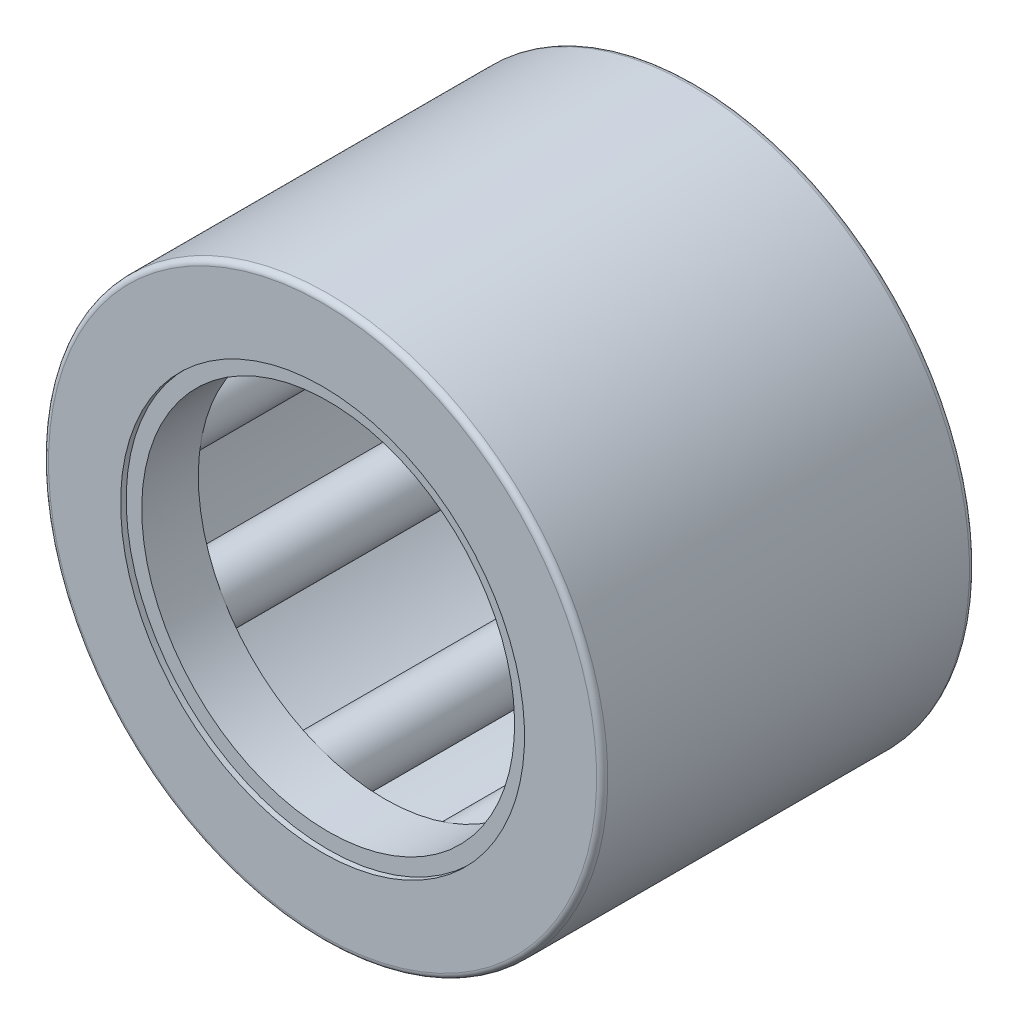
from build123d import *

# Parameters (mm, degrees)
SKETCH2_W         = 5.333333334
SKETCH2_H         = 0.5
SKETCH3_W         = 6.666666666
SKETCH3_H         = 0.166666666
CIRPATTERN1_COUNT = 9
CIRPATTERN1_ANGLE = 320
FILLET1_R         = 0.12
SKETCH4_W         = 1.213333333
SKETCH4_H         = 0.333333333
SKETCH5_W         = 1.213333333
SKETCH5_H         = 0.333333333


with BuildPart() as part:
    # Sketch7 → Revolve1 (revolve)
    with BuildSketch(Plane(origin=(0, 0, 0), x_dir=(0, 0, -1), z_dir=(1, 0, 0))):
        Polygon((-4, 6), (-4, 4.333333333), (-3.333333333, 4.333333333), (-3.333333333, 5.333333333), (3.333333333, 5.333333333), (3.333333333, 4.333333333), (4, 4.333333333), (4, 6), align=None)
    revolve(axis=Axis((0, 0, 4), (0, 0, -1)))

    # Fillet1
    fillet1_edges = [part.edges().sort_by_distance(p)[0] for p in [
        (0, -6, -4),
        (0, -6, 4),
    ]]
    fillet(fillet1_edges, radius=FILLET1_R)


with BuildPart() as body_2:
    # Sketch2 → Revolve2 (revolve)
    with BuildSketch(Plane(origin=(0, 0, 0), x_dir=(0, 0, -1), z_dir=(1, 0, 0))):
        with Locations((0, 5.083333333)):
            Rectangle(SKETCH2_W, SKETCH2_H)
    revolve(axis=Axis((0, 4.666666667, 2.666666667), (0, 0, -1)))


with BuildPart() as body_3:
    # Sketch3 → Revolve3 (revolve)
    with BuildSketch(Plane(origin=(0, 0, 0), x_dir=(0, 0, -1), z_dir=(1, 0, 0))):
        with Locations((0, 4.75)):
            Rectangle(SKETCH3_W, SKETCH3_H)
    revolve(axis=Axis((0, 4.666666667, 3.333333333), (0, 0, -1)))


with BuildPart() as cirpattern1_1:
    # CirPattern1: pattern copy
    add(body_2.part.rotate(Axis((0, 0, 4), (0, 0, -1)), 1 * CIRPATTERN1_ANGLE / (CIRPATTERN1_COUNT - 1)))


with BuildPart() as cirpattern1_2:
    # CirPattern1: pattern copy
    add(body_2.part.rotate(Axis((0, 0, 4), (0, 0, -1)), 2 * CIRPATTERN1_ANGLE / (CIRPATTERN1_COUNT - 1)))


with BuildPart() as cirpattern1_3:
    # CirPattern1: pattern copy
    add(body_2.part.rotate(Axis((0, 0, 4), (0, 0, -1)), 3 * CIRPATTERN1_ANGLE / (CIRPATTERN1_COUNT - 1)))


with BuildPart() as cirpattern1_4:
    # CirPattern1: pattern copy
    add(body_2.part.rotate(Axis((0, 0, 4), (0, 0, -1)), 4 * CIRPATTERN1_ANGLE / (CIRPATTERN1_COUNT - 1)))


with BuildPart() as cirpattern1_5:
    # CirPattern1: pattern copy
    add(body_2.part.rotate(Axis((0, 0, 4), (0, 0, -1)), 5 * CIRPATTERN1_ANGLE / (CIRPATTERN1_COUNT - 1)))


with BuildPart() as cirpattern1_6:
    # CirPattern1: pattern copy
    add(body_2.part.rotate(Axis((0, 0, 4), (0, 0, -1)), 6 * CIRPATTERN1_ANGLE / (CIRPATTERN1_COUNT - 1)))


with BuildPart() as cirpattern1_7:
    # CirPattern1: pattern copy
    add(body_2.part.rotate(Axis((0, 0, 4), (0, 0, -1)), 7 * CIRPATTERN1_ANGLE / (CIRPATTERN1_COUNT - 1)))


with BuildPart() as cirpattern1_8:
    # CirPattern1: pattern copy
    add(body_2.part.rotate(Axis((0, 0, 4), (0, 0, -1)), 8 * CIRPATTERN1_ANGLE / (CIRPATTERN1_COUNT - 1)))


with BuildPart() as cirpattern1_9:
    # CirPattern1: pattern copy
    add(body_3.part.rotate(Axis((0, 0, 4), (0, 0, -1)), 1 * CIRPATTERN1_ANGLE / (CIRPATTERN1_COUNT - 1)))


with BuildPart() as cirpattern1_10:
    # CirPattern1: pattern copy
    add(body_3.part.rotate(Axis((0, 0, 4), (0, 0, -1)), 2 * CIRPATTERN1_ANGLE / (CIRPATTERN1_COUNT - 1)))


with BuildPart() as cirpattern1_11:
    # CirPattern1: pattern copy
    add(body_3.part.rotate(Axis((0, 0, 4), (0, 0, -1)), 3 * CIRPATTERN1_ANGLE / (CIRPATTERN1_COUNT - 1)))


with BuildPart() as cirpattern1_12:
    # CirPattern1: pattern copy
    add(body_3.part.rotate(Axis((0, 0, 4), (0, 0, -1)), 4 * CIRPATTERN1_ANGLE / (CIRPATTERN1_COUNT - 1)))


with BuildPart() as cirpattern1_13:
    # CirPattern1: pattern copy
    add(body_3.part.rotate(Axis((0, 0, 4), (0, 0, -1)), 5 * CIRPATTERN1_ANGLE / (CIRPATTERN1_COUNT - 1)))


with BuildPart() as cirpattern1_14:
    # CirPattern1: pattern copy
    add(body_3.part.rotate(Axis((0, 0, 4), (0, 0, -1)), 6 * CIRPATTERN1_ANGLE / (CIRPATTERN1_COUNT - 1)))


with BuildPart() as cirpattern1_15:
    # CirPattern1: pattern copy
    add(body_3.part.rotate(Axis((0, 0, 4), (0, 0, -1)), 7 * CIRPATTERN1_ANGLE / (CIRPATTERN1_COUNT - 1)))


with BuildPart() as cirpattern1_16:
    # CirPattern1: pattern copy
    add(body_3.part.rotate(Axis((0, 0, 4), (0, 0, -1)), 8 * CIRPATTERN1_ANGLE / (CIRPATTERN1_COUNT - 1)))


with BuildPart() as body_20:
    # Sketch4 → Revolve4 (revolve)
    with BuildSketch(Plane(origin=(0, 0, 0), x_dir=(0, 0, -1), z_dir=(1, 0, 0))):
        with Locations((3.273333334, 4.166666667)):
            Rectangle(SKETCH4_W, SKETCH4_H)
    revolve(axis=Axis((0, 0, 4), (0, 0, -1)))


with BuildPart() as body_21:
    # Sketch5 → Revolve5 (revolve)
    with BuildSketch(Plane(origin=(0, 0, 0), x_dir=(0, 0, -1), z_dir=(1, 0, 0))):
        with Locations((-3.273333334, 4.166666667)):
            Rectangle(SKETCH5_W, SKETCH5_H)
    revolve(axis=Axis((0, 0, 4), (0, 0, -1)))


solid = Compound([part.part, body_2.part, body_3.part, cirpattern1_1.part, cirpattern1_2.part, cirpattern1_3.part, cirpattern1_4.part, cirpattern1_5.part, cirpattern1_6.part, cirpattern1_7.part, cirpattern1_8.part, cirpattern1_9.part, cirpattern1_10.part, cirpattern1_11.part, cirpattern1_12.part, cirpattern1_13.part, cirpattern1_14.part, cirpattern1_15.part, cirpattern1_16.part, body_20.part, body_21.part])
